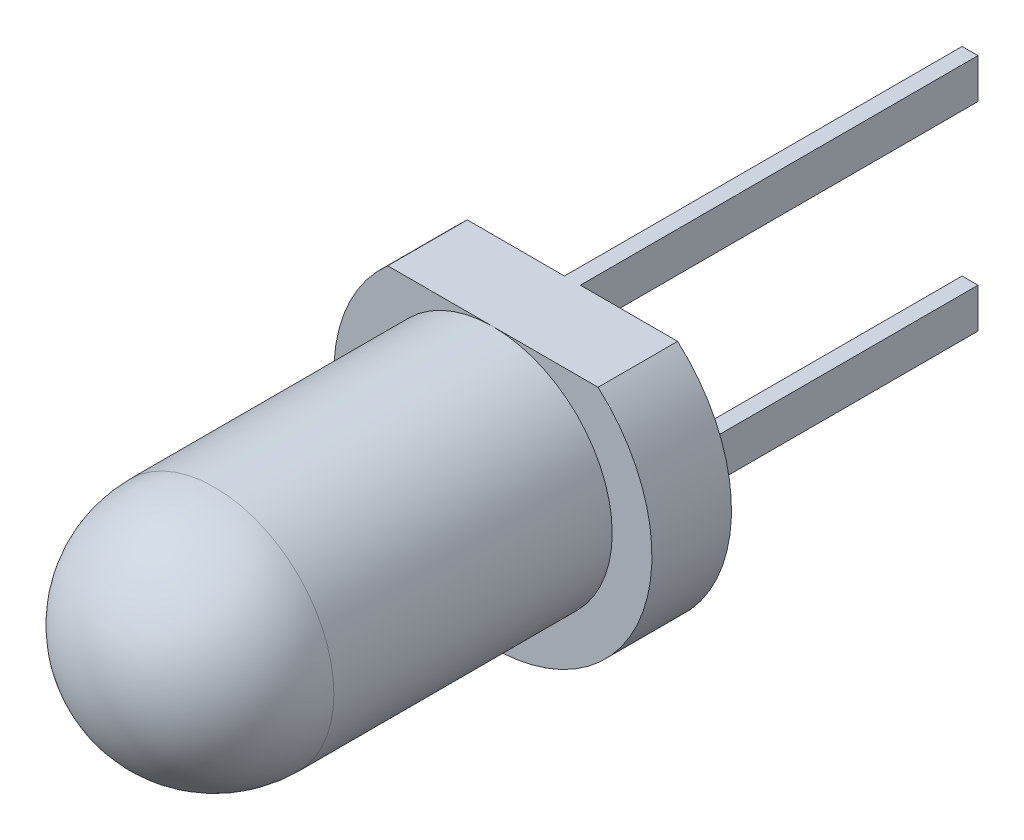
from build123d import *

# Parameters (mm, degrees)
SKETCH1_R               = 1.5
BASE_EXTRUDE_DEPTH      = 3.5
DOME1_FACE_RADIUS       = 1.5
DOME1_HEIGHT            = 1.5
SKETCH2_R               = 2
BOSS_EXTRUDE1_DEPTH     = 1
SKETCH3_W               = 0.2
SKETCH3_H               = 0.5
BOSS_EXTRUDE2_DEPTH     = 5
CUT_EXTRUDE1_DEPTH      = 6
CUT_EXTRUDE1_DEPTH_BACK = 7


with BuildPart() as part:
    # Sketch1 → Base-Extrude (new body)
    with BuildSketch(Plane.XY):
        Circle(SKETCH1_R)
    extrude(amount=BASE_EXTRUDE_DEPTH)

    # Dome1: a dome of height H over a round flat face of radius A is a cap of a sphere of radius (A * A + H * H) / (2 * H)
    dome1_r = (DOME1_FACE_RADIUS * DOME1_FACE_RADIUS + DOME1_HEIGHT * DOME1_HEIGHT) / (2 * DOME1_HEIGHT)
    dome1_base = Plane((0, 0, 3.5), z_dir=(0, 0, 1))
    with Locations(dome1_base.offset(DOME1_HEIGHT - dome1_r)):
        dome1_ball = Sphere(dome1_r, mode=Mode.PRIVATE)
    add(split(dome1_ball, bisect_by=dome1_base, keep=Keep.TOP, mode=Mode.PRIVATE))

    # Sketch2 → Boss-Extrude1 (add)
    with BuildSketch(Plane(origin=(0, 0, 0), x_dir=(-1, 0, 0), z_dir=(0, 0, -1))):
        Circle(SKETCH2_R)
    extrude(amount=BOSS_EXTRUDE1_DEPTH)

    # Sketch3 → Boss-Extrude2 (add)
    with BuildSketch(Plane(origin=(0, 0, -1), x_dir=(-1, 0, 0), z_dir=(0, 0, -1))):
        with Locations((0, 1.25)):
            Rectangle(SKETCH3_W, SKETCH3_H)
        with Locations((0, -1.25)):
            Rectangle(SKETCH3_W, SKETCH3_H)
    extrude(amount=BOSS_EXTRUDE2_DEPTH)

    # Sketch5 → Cut-Extrude1 (cut, two sides)
    with BuildSketch(Plane(origin=(0, 0, -1), x_dir=(-1, 0, 0), z_dir=(0, 0, -1))) as cut_extrude1_sk:
        Polygon((-20.975129822, 1.5), (-1.322875656, 1.5), (1.322875656, 1.5), (20.975129822, 1.5), (20.975129822, 40.804508332), (-20.975129822, 40.804508332), align=None)
    extrude(amount=CUT_EXTRUDE1_DEPTH, mode=Mode.SUBTRACT)
    extrude(cut_extrude1_sk.sketch, amount=-CUT_EXTRUDE1_DEPTH_BACK, mode=Mode.SUBTRACT)


solid = part.part
